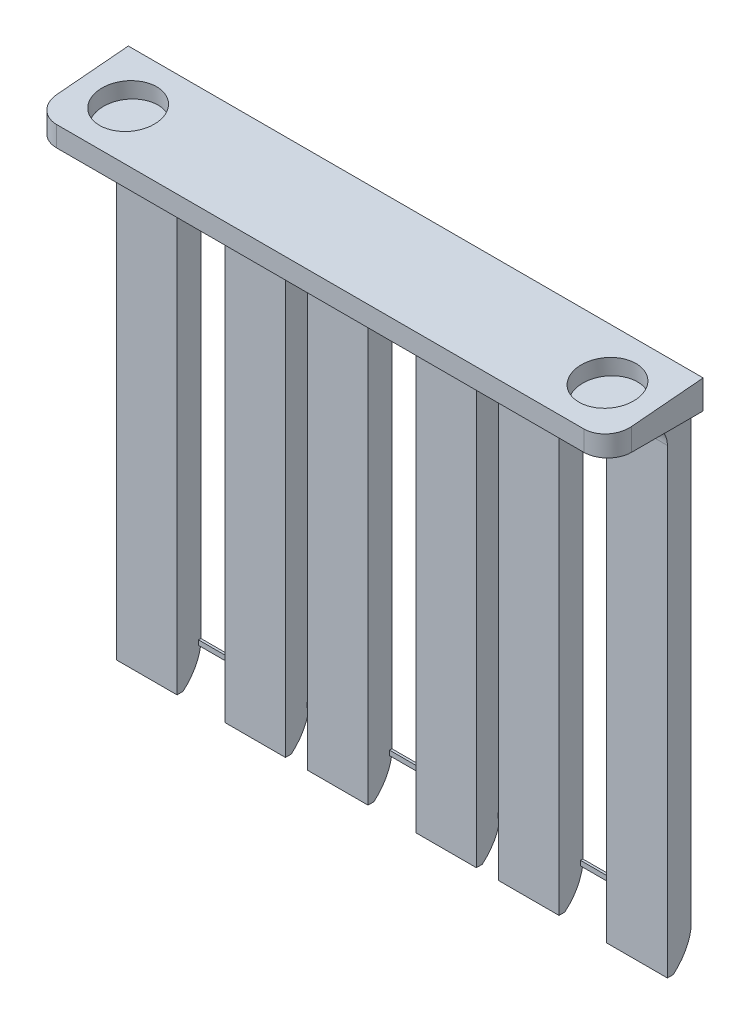
from build123d import *

# Parameters (mm, degrees)
BOSS_EXTRUDE1_DEPTH = 5
BOSS_EXTRUDE2_DEPTH = 20
CUT_EXTRUDE1_DEPTH  = 157.917080014
FILLET1_R           = 5
CUT_EXTRUDE6_DEPTH  = 159.804030176
SKETCH5_R           = 6
CUT_EXTRUDE7_DEPTH  = 3.5
FILLET2_R           = 5
SKETCH6_W           = 115.4
SKETCH6_H           = 1
BOSS_EXTRUDE3_DEPTH = 0.5


with BuildPart() as part:
    # Sketch1 → Boss-Extrude1 (new body)
    with BuildSketch(Plane.XY):
        Polygon((25.2, 0), (25.2, -101.6), (37.9, -101.6), (37.9, 0), (42.5, 0), (42.5, -101.6), (55.2, -101.6), (55.2, 0), (65.2, 0), (65.2, -101.6), (77.9, -101.6), (77.9, 0), (82.5, 0), (82.5, -101.6), (95.2, -101.6), (95.2, 0), (105.2, 0), (105.2, -101.6), (117.9, -101.6), (117.9, 0), (120.4, 0), (120.4, 6), (0, 6), (0, 0), (2.5, 0), (2.5, -101.6), (15.2, -101.6), (15.2, 0), align=None)
    extrude(amount=BOSS_EXTRUDE1_DEPTH)

    # Sketch1_3 → Boss-Extrude2 (add)
    with BuildSketch(Plane.XY):
        Polygon((15.2, 0), (25.2, 0), (37.9, 0), (42.5, 0), (55.2, 0), (65.2, 0), (77.9, 0), (82.5, 0), (95.2, 0), (105.2, 0), (117.9, 0), (120.4, 0), (120.4, 6), (0, 6), (0, 0), (2.5, 0), align=None)
    extrude(amount=BOSS_EXTRUDE2_DEPTH)

    # Sketch2 → Cut-Extrude1 (cut, through all)
    with BuildSketch(Plane(origin=(117.9, 0, 0), x_dir=(0, 0, -1), z_dir=(1, 0, 0))):
        with BuildLine():
            Line((-3.771412758, -101.6), (0, -101.6))
            Line((0, -101.6), (0, -94.860498406))
            ThreePointArc((0, -94.860498406), (-1.259194033, -98.580844365), (-3.771412758, -101.6))
        make_face()
    extrude(amount=-CUT_EXTRUDE1_DEPTH, mode=Mode.SUBTRACT)

    # Fillet1
    fillet1_edges = [part.edges().sort_by_distance(p)[0] for p in [
        (8.85, 0, 5),
        (31.55, 0, 5),
        (48.85, 0, 5),
        (71.55, 0, 5),
        (88.85, 0, 5),
        (111.55, 0, 5),
    ]]
    fillet(fillet1_edges, radius=FILLET1_R)

    # Sketch4 → Cut-Extrude6 (cut, through all)
    with BuildSketch(Plane(origin=(120.4, 0, 0), x_dir=(0, 0, -1), z_dir=(1, 0, 0))):
        Polygon((0, 6), (-20, 4.250226729), (-20, 6), align=None)
    extrude(amount=-CUT_EXTRUDE6_DEPTH, mode=Mode.SUBTRACT)

    # Sketch5 → Cut-Extrude7 (cut)
    with BuildSketch(Plane(origin=(0, 5.954423259, 0.520944533), x_dir=(1, 0, 0), z_dir=(0, 0.9961946980917462, 0.08715574274765159))):
        with Locations(Location((110.4, -9.553462294, 0), (0, 0, 270))):
            Circle(SKETCH5_R)
        with Locations(Location((10, -9.553462294, 0), (0, 0, 270))):
            Circle(SKETCH5_R)
    extrude(amount=-CUT_EXTRUDE7_DEPTH, mode=Mode.SUBTRACT)

    # Fillet2
    fillet2_edges = [part.edges().sort_by_distance(p)[0] for p in [
        (0, 2.125113365, 20),
        (120.4, 2.125113365, 20),
    ]]
    fillet(fillet2_edges, radius=FILLET2_R)

    # Sketch6 → Boss-Extrude3 (add)
    with BuildSketch(Plane.XY):
        with Locations((60.2, -94.360498406)):
            Rectangle(SKETCH6_W, SKETCH6_H)
    extrude(amount=BOSS_EXTRUDE3_DEPTH)


solid = part.part
